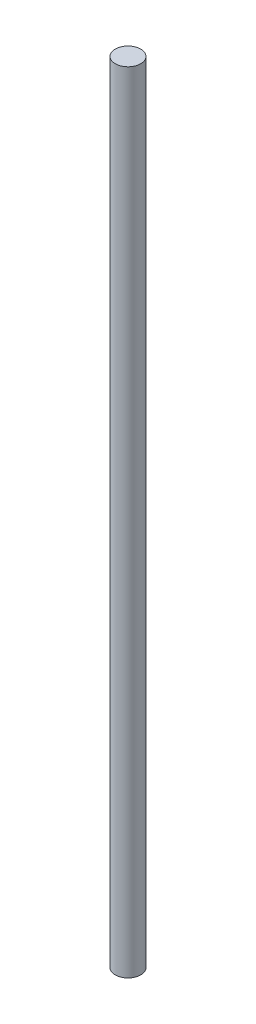
from build123d import *

# Parameters (mm, degrees)
SKETCH1_R           = 2.5
BOSS_EXTRUDE1_DEPTH = 155


with BuildPart() as part:
    # Sketch1 → Boss-Extrude1 (new body)
    with BuildSketch(Plane(origin=(0, 0, 0), x_dir=(1, 0, 0), z_dir=(0, 1, 0))):
        Circle(SKETCH1_R)
    extrude(amount=BOSS_EXTRUDE1_DEPTH)


solid = part.part
